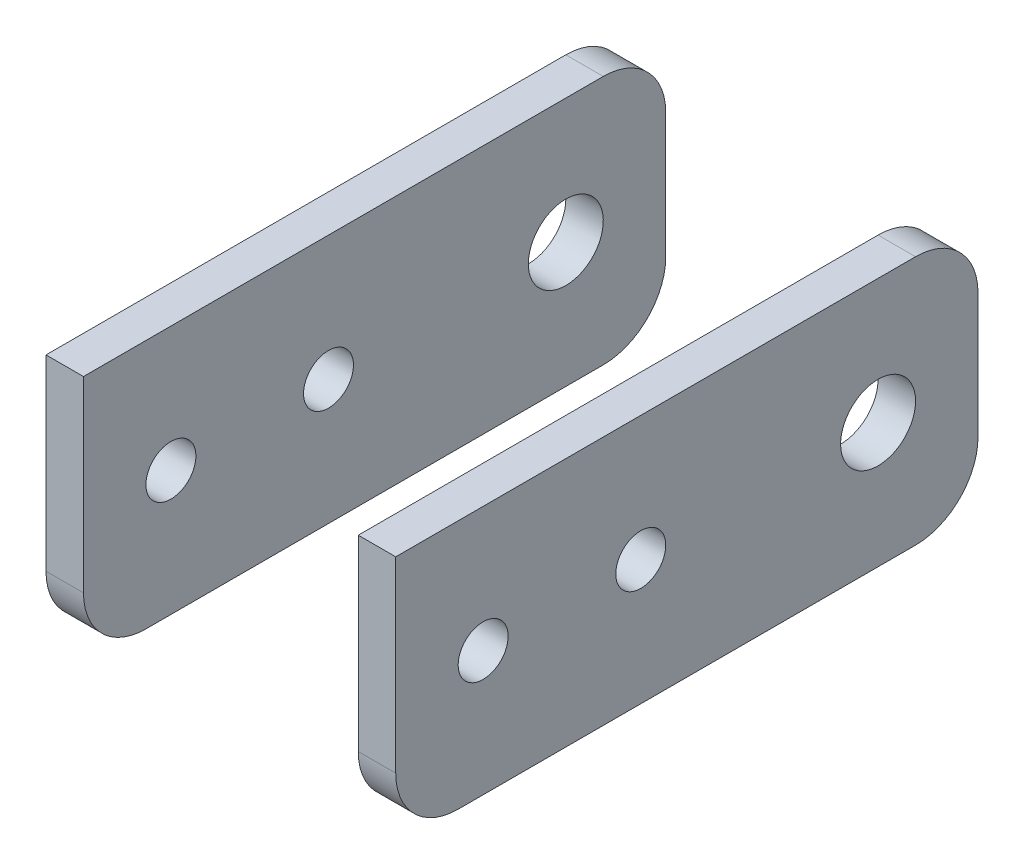
from build123d import *

# Parameters (mm, degrees)
SZKIC1_R                        = 2
SZKIC1_R_2                      = 3
DODANIE_WYCI_GNI_CIE1_DEPTH     = 14
SZKIC2_W                        = 22
SZKIC2_H                        = 20
WYTNIJ_WYCI_GNI_CIE1_DEPTH      = 32.61688289
WYTNIJ_WYCI_GNI_CIE1_DEPTH_BACK = 16


with BuildPart() as part:
    # Szkic1 → Dodanie-wyciągnięcie1 (new body, symmetric)
    with BuildSketch(Plane(origin=(0, 0, 0), x_dir=(0, 0, -1), z_dir=(1, 0, 0))):
        with BuildLine():
            Line((0, 0), (-26.61688289, 0))
            ThreePointArc((-26.61688289, 0), (-30.152416796, 1.464466094), (-31.61688289, 5))
            Line((-31.61688289, 5), (-31.61688289, 20))
            Line((-31.61688289, 20), (5, 20))
            Line((5, 20), (10, 20))
            ThreePointArc((10, 20), (13.535533906, 18.535533906), (15, 15))
            Line((15, 15), (15, 5))
            ThreePointArc((15, 5), (13.535533906, 1.464466094), (10, 0))
            Line((10, 0), (0, 0))
        make_face()
        with Locations((-24.61688289, 10)):
            Circle(SZKIC1_R, mode=Mode.SUBTRACT)
        with Locations((-12, 10)):
            Circle(SZKIC1_R, mode=Mode.SUBTRACT)
        with Locations((7, 10)):
            Circle(SZKIC1_R_2, mode=Mode.SUBTRACT)
    extrude(amount=DODANIE_WYCI_GNI_CIE1_DEPTH, both=True)

    # Szkic2 → Wytnij-wyciągnięcie1 (cut, two sides)
    with BuildSketch(Plane.XY) as wytnij_wyci_gni_cie1_sk:
        with Locations((0, 10)):
            Rectangle(SZKIC2_W, SZKIC2_H)
    extrude(amount=WYTNIJ_WYCI_GNI_CIE1_DEPTH, mode=Mode.SUBTRACT)
    extrude(wytnij_wyci_gni_cie1_sk.sketch, amount=-WYTNIJ_WYCI_GNI_CIE1_DEPTH_BACK, mode=Mode.SUBTRACT)


solid = part.part
